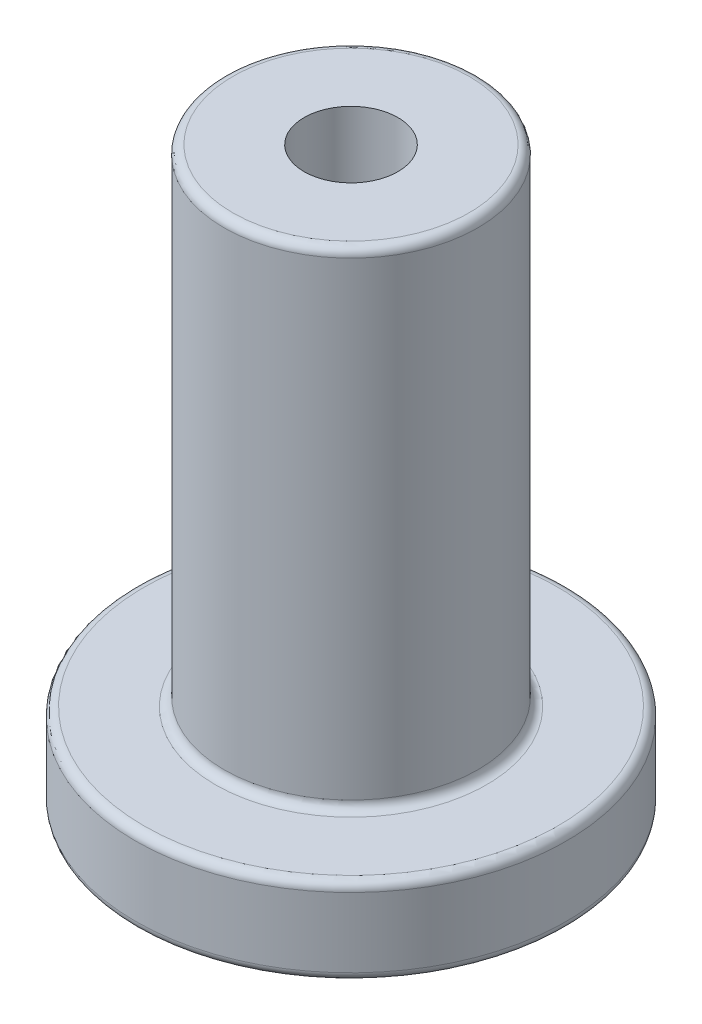
from build123d import *

# Parameters (mm, degrees)
SKETCH1_R           = 12.4
BOSS_EXTRUDE1_DEPTH = 5
SKETCH2_R           = 7.3
BOSS_EXTRUDE2_DEPTH = 28
SKETCH3_R           = 2.7
CUT_EXTRUDE1_DEPTH  = 34
CUT_EXTRUDE2_DEPTH  = 3
FILLET1_R           = 0.5


with BuildPart() as part:
    # Sketch1 → Boss-Extrude1 (new body)
    with BuildSketch(Plane(origin=(0, 0, 0), x_dir=(1, 0, 0), z_dir=(0, 1, 0))):
        Circle(SKETCH1_R)
    extrude(amount=BOSS_EXTRUDE1_DEPTH)

    # Sketch2 → Boss-Extrude2 (add)
    with BuildSketch(Plane(origin=(0, 5, 0), x_dir=(1, 0, 0), z_dir=(0, 1, 0))):
        Circle(SKETCH2_R)
    extrude(amount=BOSS_EXTRUDE2_DEPTH)

    # Sketch3 → Cut-Extrude1 (cut, through all)
    with BuildSketch(Plane(origin=(0, 33, 0), x_dir=(1, 0, 0), z_dir=(0, 1, 0))):
        Circle(SKETCH3_R)
    extrude(amount=-CUT_EXTRUDE1_DEPTH, mode=Mode.SUBTRACT)

    # Sketch4 → Cut-Extrude2 (cut)
    with BuildSketch(Plane.XZ):
        Polygon((-4.38019792, 2.081793981), (-3.992985433, -2.752465682), (0.387212487, -4.834259663), (4.38019792, -2.081793981), (3.992985433, 2.752465682), (-0.387212487, 4.834259663), align=None)
    extrude(amount=-CUT_EXTRUDE2_DEPTH, mode=Mode.SUBTRACT)

    # Fillet1
    fillet1_edges = [part.edges().sort_by_distance(p)[0] for p in [
        (-12.4, 0, 0),
        (-12.4, 5, 0),
        (-7.3, 5, 0),
        (-7.3, 33, 0),
    ]]
    fillet(fillet1_edges, radius=FILLET1_R)


solid = part.part
